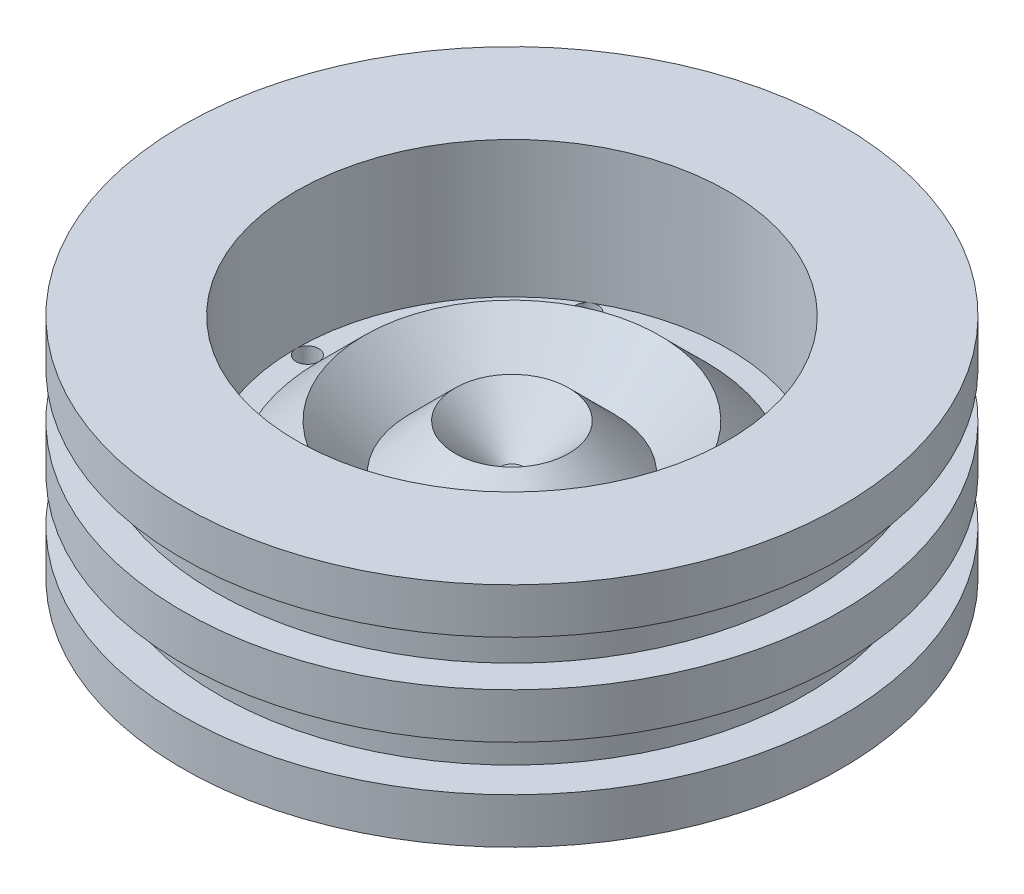
from build123d import *

# Parameters (mm, degrees)
SKETCH2_R          = 2.5
CUT_EXTRUDE1_DEPTH = 30


with BuildPart() as part:
    # Sketch1 → Revolve1 (revolve)
    with BuildSketch(Plane.XY):
        Polygon((-72.5, 0), (0, 0), (0, 20), (-2.5, 20), (-12.5, 30), (-22.5, 20), (-32.5, 30), (-42.5, 20), (-47.5, 20), (-47.5, 50), (-72.5, 50), (-72.5, 40), (-65.326285386, 40), (-65.326285386, 30), (-72.5, 30), (-72.5, 20), (-64.5, 20), (-64.5, 10), (-72.5, 10), align=None)
    revolve(axis=Axis((0, 20, 0), (0, -1, 0)))

    # Sketch2 → Cut-Extrude1 (cut)
    with BuildSketch(Plane.XZ):
        with BuildLine():
            ThreePointArc((-47.5, 0), (-45, -2.5), (-42.5, 0))
            Line((-42.5, 0), (-47.5, 0))
        make_face()
        with BuildLine():
            Line((-47.5, 0), (-42.5, 0))
            ThreePointArc((-42.5, 0), (-45, 2.5), (-47.5, 0))
        make_face()
        with Locations((-22.5, -38.97114317)):
            Circle(SKETCH2_R)
        with Locations((-22.5, 38.97114317)):
            Circle(SKETCH2_R)
        with Locations((22.5, 38.97114317)):
            Circle(SKETCH2_R)
        with Locations((45, 0)):
            Circle(SKETCH2_R)
        with Locations((22.5, -38.97114317)):
            Circle(SKETCH2_R)
    extrude(amount=-CUT_EXTRUDE1_DEPTH, mode=Mode.SUBTRACT)


solid = part.part
